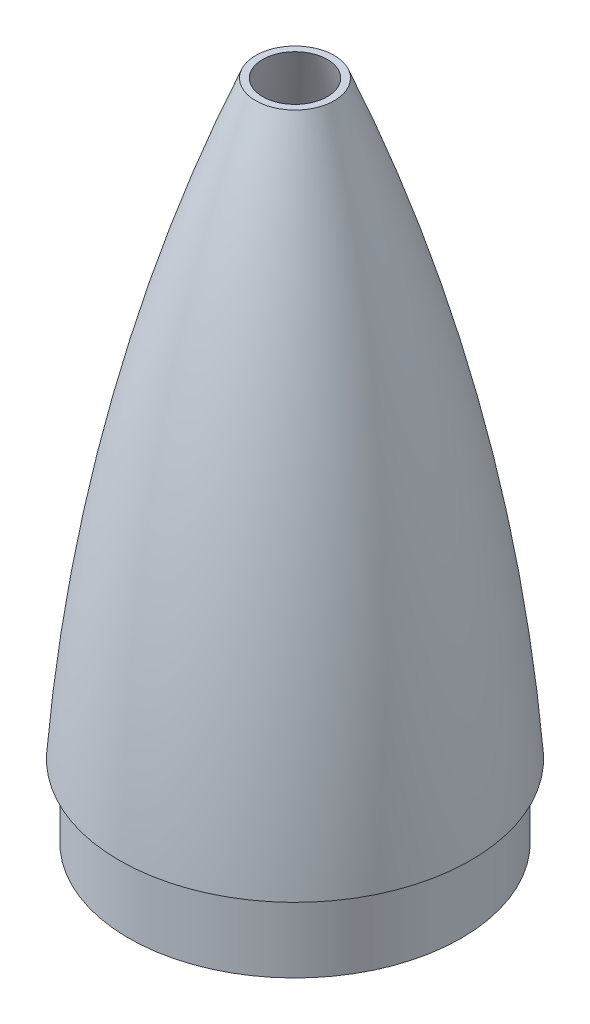
from build123d import *

# Parameters (mm, degrees)
SKETCH4_R           = 93.1545
SKETCH4_R_2         = 90.4875
BOSS_EXTRUDE2_DEPTH = 40.3999954
SKETCH7_R           = 317.5
CUT_EXTRUDE2_DEPTH  = 50.8


with BuildPart() as part:
    # Sketch2 → Revolve1 (revolve)
    with BuildSketch(Plane.XY):
        with BuildLine():
            Line((-98.425, 0), (-90.551, 0))
            ThreePointArc((-90.551, 0), (-60.43106349, 191.610647557), (0, 375.92))
            Line((0, 375.92), (0, 381))
            ThreePointArc((0, 381), (-66.494117829, 194.964417939), (-98.425, 0))
        make_face()
    revolve(axis=Axis((0, 381, 0), (0, -1, 0)))

    # Sketch4 → Boss-Extrude2 (add)
    with BuildSketch(Plane(origin=(0, 0, 0), x_dir=(-1, 0, 0), z_dir=(0, -1, 0))):
        Circle(SKETCH4_R)
        Circle(SKETCH4_R_2, mode=Mode.SUBTRACT)
    extrude(amount=BOSS_EXTRUDE2_DEPTH)

    # Sketch7 → Cut-Extrude2 (cut)
    with BuildSketch(Plane(origin=(0, 381, 0), x_dir=(1, 0, 0), z_dir=(0, 1, 0))):
        Circle(SKETCH7_R)
    extrude(amount=-CUT_EXTRUDE2_DEPTH, mode=Mode.SUBTRACT)


solid = part.part
